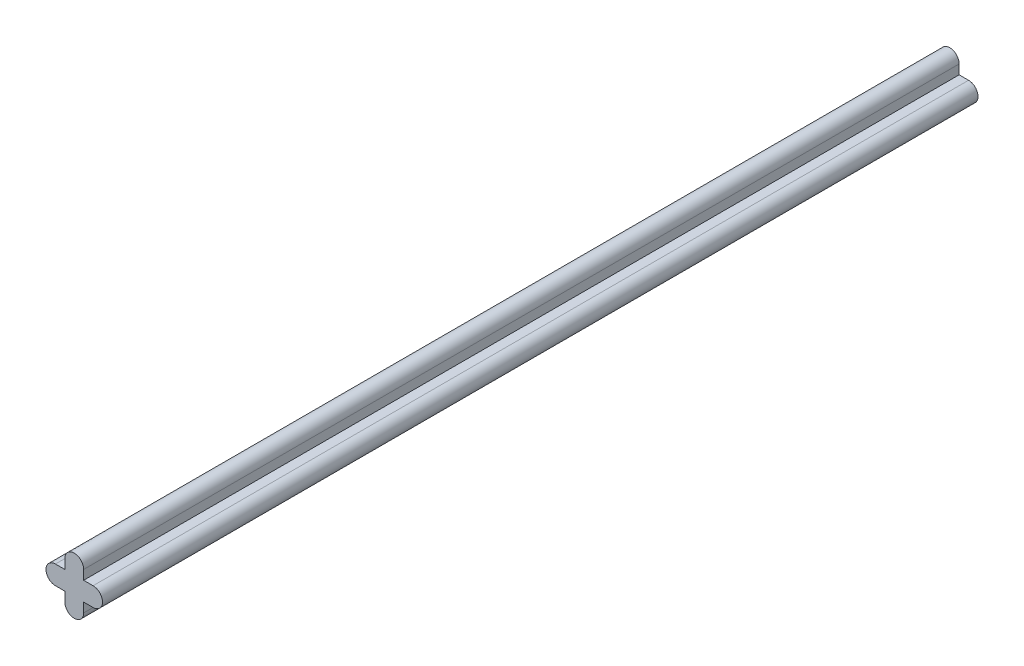
from build123d import *

# Parameters (mm, degrees)
BOSS_EXTRUDE1_DEPTH = 70.866


with BuildPart() as part:
    # Sketch1 → Boss-Extrude1 (new body)
    with BuildSketch(Plane.XY):
        with BuildLine():
            Line((-0.762, 0.762), (-1.524, 0.762))
            ThreePointArc((-1.524, 0.762), (-2.286, 0), (-1.524, -0.762))
            Line((-1.524, -0.762), (-0.762, -0.762))
            Line((-0.762, -0.762), (-0.762, -1.524))
            ThreePointArc((-0.762, -1.524), (0, -2.286), (0.762, -1.524))
            Line((0.762, -1.524), (0.762, -0.762))
            Line((0.762, -0.762), (1.524, -0.762))
            ThreePointArc((1.524, -0.762), (2.286, 0), (1.524, 0.762))
            Line((1.524, 0.762), (0.762, 0.762))
            Line((0.762, 0.762), (0.762, 1.524))
            ThreePointArc((0.762, 1.524), (0, 2.286), (-0.762, 1.524))
            Line((-0.762, 1.524), (-0.762, 0.762))
        make_face()
    extrude(amount=BOSS_EXTRUDE1_DEPTH)


solid = part.part
